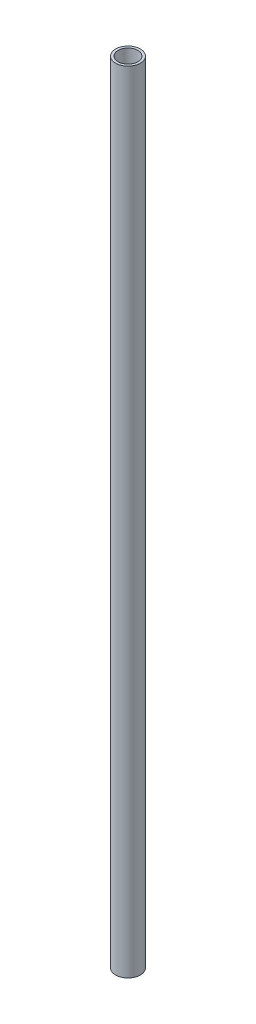
from build123d import *

# Parameters (mm, degrees)
SKETCH1_R           = 7.9375
SKETCH1_R_2         = 6.35
BOSS_EXTRUDE1_DEPTH = 508


with BuildPart() as part:
    # Sketch1 → Boss-Extrude1 (new body)
    with BuildSketch(Plane(origin=(0, 0, 0), x_dir=(1, 0, 0), z_dir=(0, 1, 0))):
        Circle(SKETCH1_R)
        Circle(SKETCH1_R_2, mode=Mode.SUBTRACT)
    extrude(amount=BOSS_EXTRUDE1_DEPTH)


solid = part.part
